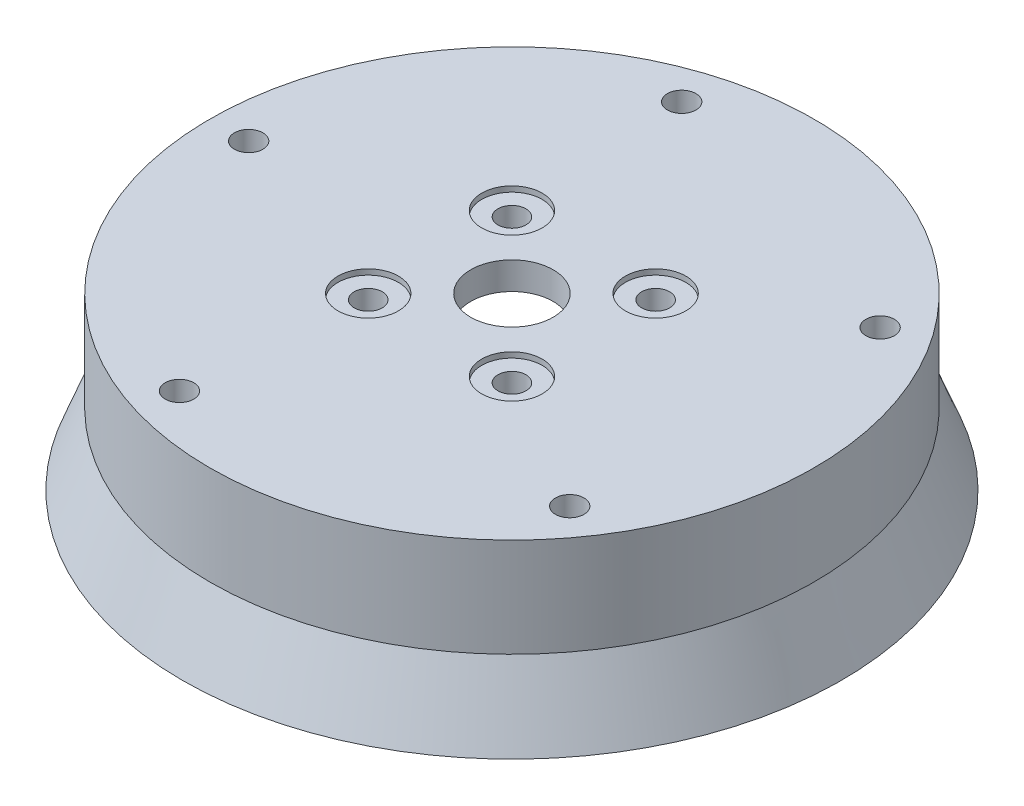
from build123d import *

# Parameters (mm, degrees)
SKETCH2_R          = 2.59748937
CUT_EXTRUDE1_DEPTH = 91.338253249
CUT_EXTRUDE3_START = -27
SKETCH3_R          = 4
CUT_EXTRUDE3_DEPTH = 27
SKETCH4_R          = 2.55
CUT_EXTRUDE4_DEPTH = 91.338253283
SKETCH5_R          = 5.5
CUT_EXTRUDE5_DEPTH = 1


with BuildPart() as part:
    # Sketch1 → Revolve1 (revolve)
    with BuildSketch(Plane.XY, mode=Mode.PRIVATE) as revolve1_sk:
        Polygon((-60, -31), (-55, -18), (-55, 0), (-7.5, 0), (-7.5, -5), (-26.5, -5), (-26.5, -6.00446503), (-52, -31), align=None)
    revolve(revolve1_sk.sketch.rotate(Axis((0, 0, 0), (0, -1, 0)), 270), axis=Axis((0, 0, 0), (0, -1, 0)))

    # Sketch2 → Cut-Extrude1 (cut, through all)
    with BuildSketch(Plane(origin=(0, 0, 0), x_dir=(1, 0, 0), z_dir=(0, 1, 0))):
        with Locations(Location((-47.999950054, 0.069244591, 0), (0, 0, 270))):
            Circle(SKETCH2_R)
        with Locations(Location((-14.766944776, 45.672063036, 0), (0, 0, 270))):
            Circle(SKETCH2_R)
        with Locations(Location((38.873476272, 28.157642702, 0), (0, 0, 270))):
            Circle(SKETCH2_R)
        with Locations(Location((38.792074374, -28.269682803, 0), (0, 0, 270))):
            Circle(SKETCH2_R)
        with Locations(Location((-14.898655815, -45.629267525, 0), (0, 0, 270))):
            Circle(SKETCH2_R)
    extrude(amount=-CUT_EXTRUDE1_DEPTH, mode=Mode.SUBTRACT)

    # Sketch3 → Cut-Extrude3 (cut)
    with BuildSketch(Plane.XZ.offset(31).offset(CUT_EXTRUDE3_START)):
        with Locations(Location((-47.999950054, -0.069244591, 0), (0, 0, 180.082654671))):
            Circle(SKETCH3_R)
        with Locations(Location((-14.898655815, 45.629267525, 0), (0, 0, 108.082654673))):
            Circle(SKETCH3_R)
        with Locations(Location((38.792074374, 28.269682803, 0), (0, 0, 36.082654671))):
            Circle(SKETCH3_R)
        with Locations(Location((38.873476272, -28.157642702, 0), (0, 0, 324.082654679))):
            Circle(SKETCH3_R)
        with Locations(Location((-14.766944776, -45.672063036, 0), (0, 0, 252.082654671))):
            Circle(SKETCH3_R)
    extrude(amount=CUT_EXTRUDE3_DEPTH, mode=Mode.SUBTRACT)

    # Sketch4 → Cut-Extrude4 (cut, through all)
    with BuildSketch(Plane(origin=(0, 0, 0), x_dir=(1, 0, 0), z_dir=(0, 1, 0))):
        with Locations(Location((13.081475452, 13.081475452, 0), (0, 0, 270))):
            Circle(SKETCH4_R)
        with Locations(Location((13.081475452, -13.081475452, 0), (0, 0, 270))):
            Circle(SKETCH4_R)
        with Locations(Location((-13.081475452, -13.081475452, 0), (0, 0, 270))):
            Circle(SKETCH4_R)
        with Locations(Location((-13.081475452, 13.081475452, 0), (0, 0, 270))):
            Circle(SKETCH4_R)
    extrude(amount=-CUT_EXTRUDE4_DEPTH, mode=Mode.SUBTRACT)

    # Sketch5 → Cut-Extrude5 (cut)
    with BuildSketch(Plane(origin=(0, 0, 0), x_dir=(1, 0, 0), z_dir=(0, 1, 0))):
        with Locations(Location((13.081475452, 13.081475452, 0), (0, 0, 270))):
            Circle(SKETCH5_R)
        with Locations(Location((13.081475452, -13.081475452, 0), (0, 0, 270))):
            Circle(SKETCH5_R)
        with Locations(Location((-13.081475452, -13.081475452, 0), (0, 0, 270))):
            Circle(SKETCH5_R)
        with Locations(Location((-13.081475452, 13.081475452, 0), (0, 0, 270))):
            Circle(SKETCH5_R)
    extrude(amount=-CUT_EXTRUDE5_DEPTH, mode=Mode.SUBTRACT)


solid = part.part
